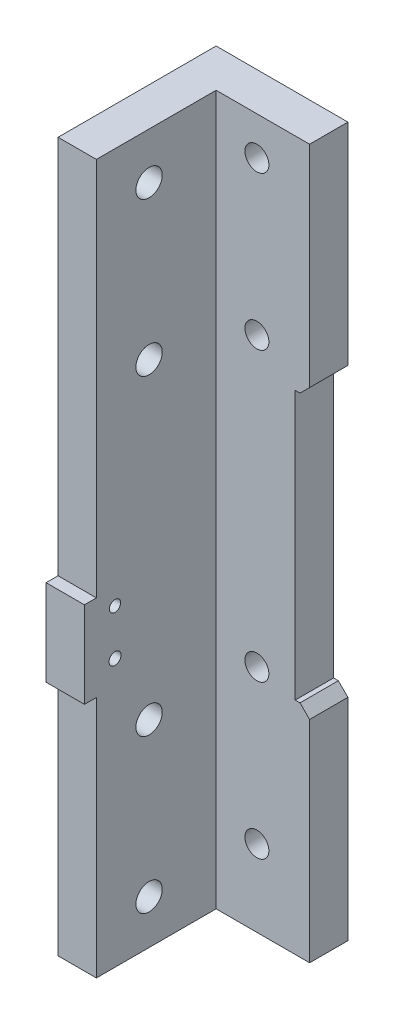
from build123d import *

# Parameters (mm, degrees)
SKETCH1_W           = 24.51
SKETCH1_H           = 148
BOSS_EXTRUDE1_DEPTH = 8
SKETCH2_W           = 8
SKETCH2_H           = 148
BOSS_EXTRUDE2_DEPTH = 25
SKETCH3_R           = 2.5
CUT_EXTRUDE1_DEPTH  = 10
SKETCH4_R           = 2.75
CUT_EXTRUDE2_DEPTH  = 8
SKETCH5_W           = 3
SKETCH5_H           = 46
BOSS_EXTRUDE3_DEPTH = 8
SKETCH6_W           = 3
SKETCH6_H           = 46
BOSS_EXTRUDE4_DEPTH = 8
CHAMFER1_SIZE       = 2
SKETCH7_W           = 6
SKETCH7_H           = 18
BOSS_EXTRUDE5_DEPTH = 8
SKETCH8_R           = 1.175
SKETCH8_R_2         = 1.25
CUT_EXTRUDE3_DEPTH  = 8


with BuildPart() as part:
    # Sketch1 → Boss-Extrude1 (new body)
    with BuildSketch(Plane.XY):
        with Locations((-12.255, 74)):
            Rectangle(SKETCH1_W, SKETCH1_H)
    extrude(amount=BOSS_EXTRUDE1_DEPTH)

    # Sketch2 → Boss-Extrude2 (add)
    with BuildSketch(Plane.XY.offset(8)):
        with Locations((-20.51, 74)):
            Rectangle(SKETCH2_W, SKETCH2_H)
    extrude(amount=BOSS_EXTRUDE2_DEPTH)

    # Sketch3 → Cut-Extrude1 (cut)
    with BuildSketch(Plane.XY.offset(8)):
        with Locations((-8, 16)):
            Circle(SKETCH3_R)
        with Locations((-8, 48)):
            Circle(SKETCH3_R)
        with Locations((-8, 108)):
            Circle(SKETCH3_R)
        with Locations((-8, 140)):
            Circle(SKETCH3_R)
    extrude(amount=-CUT_EXTRUDE1_DEPTH, mode=Mode.SUBTRACT)

    # Sketch4 → Cut-Extrude2 (cut)
    with BuildSketch(Plane.ZY.offset(24.51)):
        with Locations((22, 138.3)):
            Circle(SKETCH4_R)
        with Locations((22, 106.3)):
            Circle(SKETCH4_R)
        with Locations((22, 41.2)):
            Circle(SKETCH4_R)
        with Locations((22, 9.2)):
            Circle(SKETCH4_R)
    extrude(amount=-CUT_EXTRUDE2_DEPTH, mode=Mode.SUBTRACT)

    # Sketch5 → Boss-Extrude3 (add)
    with BuildSketch(Plane(origin=(0, 0, 0), x_dir=(-1, 0, 0), z_dir=(0, 0, -1))):
        with Locations((-1.5, 125)):
            Rectangle(SKETCH5_W, SKETCH5_H)
    extrude(amount=-BOSS_EXTRUDE3_DEPTH)

    # Sketch6 → Boss-Extrude4 (add)
    with BuildSketch(Plane(origin=(0, 0, 0), x_dir=(-1, 0, 0), z_dir=(0, 0, -1))):
        with Locations((-1.5, 23)):
            Rectangle(SKETCH6_W, SKETCH6_H)
    extrude(amount=-BOSS_EXTRUDE4_DEPTH)

    # Chamfer1
    chamfer1_edges = [part.edges().sort_by_distance(p)[0] for p in [
        (3, 46, 4),
        (3, 102, 4),
    ]]
    chamfer(chamfer1_edges, length=CHAMFER1_SIZE)

    # Sketch7 → Boss-Extrude5 (add)
    with BuildSketch(Plane.ZY.offset(24.51)):
        with Locations((32.5, 59.722248883)):
            Rectangle(SKETCH7_W, SKETCH7_H)
    extrude(amount=-BOSS_EXTRUDE5_DEPTH)

    # Sketch8 → Cut-Extrude3 (cut)
    with BuildSketch(Plane.ZY.offset(24.51)):
        with Locations((29.112052986, 65.322248883)):
            Circle(SKETCH8_R)
        with Locations((29.112052986, 55.822248883)):
            Circle(SKETCH8_R_2)
    extrude(amount=-CUT_EXTRUDE3_DEPTH, mode=Mode.SUBTRACT)


solid = part.part
